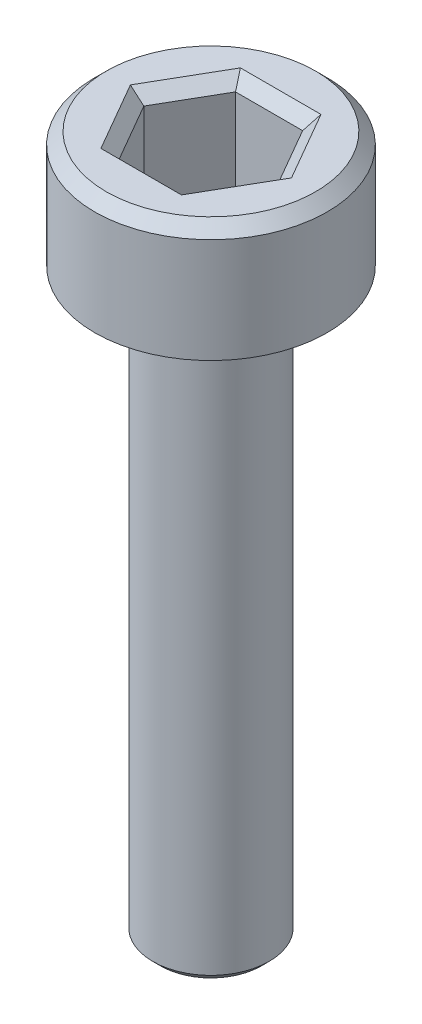
from build123d import *

# Parameters (mm, degrees)
SKETCH1_R           = 3
BOSS_EXTRUDE1_DEPTH = 3
CHAMFER1_SIZE       = 0.3
CUT_EXTRUDE1_DEPTH  = 2.5
CHAMFER2_SIZE       = 0.3
SKETCH3_R           = 1.5
BOSS_EXTRUDE2_DEPTH = 15
CHAMFER3_SIZE       = 0.2


with BuildPart() as part:
    # Sketch1 → Boss-Extrude1 (new body)
    with BuildSketch(Plane(origin=(0, 0, 0), x_dir=(1, 0, 0), z_dir=(0, 1, 0))):
        with Locations(Location((0, 0, 0), (0, 0, 270))):  # turned: the seam where the file's is
            Circle(SKETCH1_R)
    extrude(amount=BOSS_EXTRUDE1_DEPTH)

    # Chamfer1
    chamfer1_edges = [part.edges().sort_by_distance(p)[0] for p in [
        (0, 3, -3),
    ]]
    chamfer(chamfer1_edges, length=CHAMFER1_SIZE)

    # Sketch2 → Cut-Extrude1 (cut)
    with BuildSketch(Plane(origin=(0, 3, 0), x_dir=(1, 0, 0), z_dir=(0, 1, 0))):
        Polygon((1.732050808, 0), (0.866025404, 1.5), (-0.866025404, 1.5), (-1.732050808, 0), (-0.866025404, -1.5), (0.866025404, -1.5), align=None)
    extrude(amount=-CUT_EXTRUDE1_DEPTH, mode=Mode.SUBTRACT)

    # Chamfer2
    chamfer2_edges = [part.edges().sort_by_distance(p)[0] for p in [
        (1.299038106, 3, 0.75),
        (1.299038106, 3, -0.75),
        (0, 3, -1.5),
        (-1.299038106, 3, -0.75),
        (-1.299038106, 3, 0.75),
        (0, 3, 1.5),
    ]]
    chamfer(chamfer2_edges, length=CHAMFER2_SIZE)

    # Sketch3 → Boss-Extrude2 (add)
    with BuildSketch(Plane.XZ):
        with Locations(Location((0, 0, 0), (0, 0, 90))):  # turned: the seam where the file's is
            Circle(SKETCH3_R)
    extrude(amount=BOSS_EXTRUDE2_DEPTH)

    # Chamfer3
    chamfer3_edges = [part.edges().sort_by_distance(p)[0] for p in [
        (0, -15, -1.5),
    ]]
    chamfer(chamfer3_edges, length=CHAMFER3_SIZE)


solid = part.part
